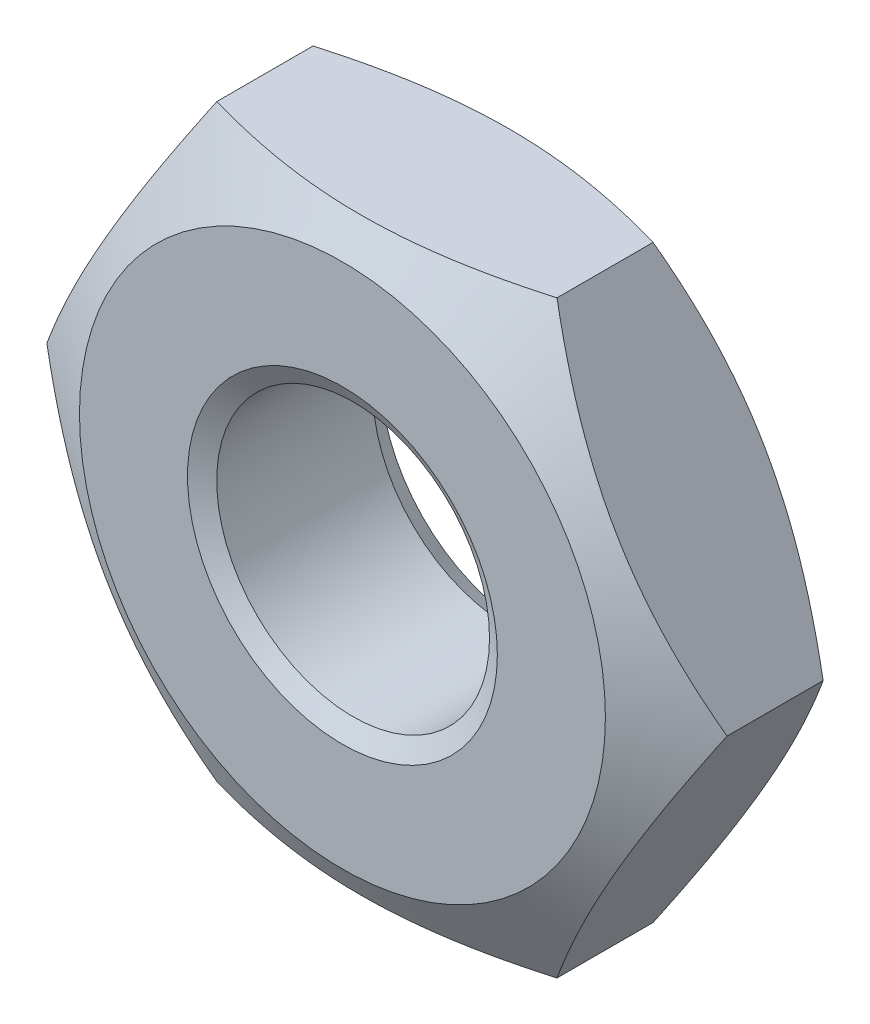
from build123d import *

# Parameters (mm, degrees)
SKETCH1_R               = 1.621
BASENUT_DEPTH           = 2.2
ENDCHAMFER_SIZE         = 0.22
ENDCHAMFER_SIZE2        = 0.127017059
ENDCHAMFER_PART_2_SIZE  = 0.22
ENDCHAMFER_PART_2_SIZE2 = 0.127017059


with BuildPart() as part:
    # Sketch1 → BaseNut (new body)
    with BuildSketch(Plane.XY):
        Polygon((2.020725942, -3.5), (4.041451884, 0), (2.020725942, 3.5), (-2.020725942, 3.5), (-4.041451884, 0), (-2.020725942, -3.5), align=None)
        Circle(SKETCH1_R, mode=Mode.SUBTRACT)
    extrude(amount=-BASENUT_DEPTH)

    # Sketch2 → Double-Chamfer (revolve, cut)
    with BuildSketch(Plane(origin=(0, 0, 0), x_dir=(1, 0, 0), z_dir=(0, 1, 0))):
        Polygon((-4.041451884, 2.2), (-3.125, 2.2), (-4.041451884, 1.670886258), align=None)
        Polygon((-4.041451884, 0.529113742), (-4.041451884, 0), (-3.125, 0), align=None)
    revolve(axis=Axis((0, 0, -3.375940562), (0, 0, 1)), mode=Mode.SUBTRACT)

    # EndChamfer
    endchamfer_edges = [part.edges().sort_by_distance(p)[0] for p in [
        (-1.621, 0, -2.2),
    ]]
    endchamfer_side = [part.faces().sort_by_distance(p)[0] for p in [
        (-1.621, 0, -1.1),
    ]]
    chamfer(endchamfer_edges, length=ENDCHAMFER_SIZE, length2=ENDCHAMFER_SIZE2, reference=endchamfer_side[0])

    # EndChamfer part 2
    endchamfer_part_2_edges = [part.edges().sort_by_distance(p)[0] for p in [
        (-1.621, 0, 0),
    ]]
    endchamfer_part_2_side = [part.faces().sort_by_distance(p)[0] for p in [
        (3.036611652, 0, 0),
    ]]
    chamfer(endchamfer_part_2_edges, length=ENDCHAMFER_PART_2_SIZE, length2=ENDCHAMFER_PART_2_SIZE2, reference=endchamfer_part_2_side[0])


solid = part.part
